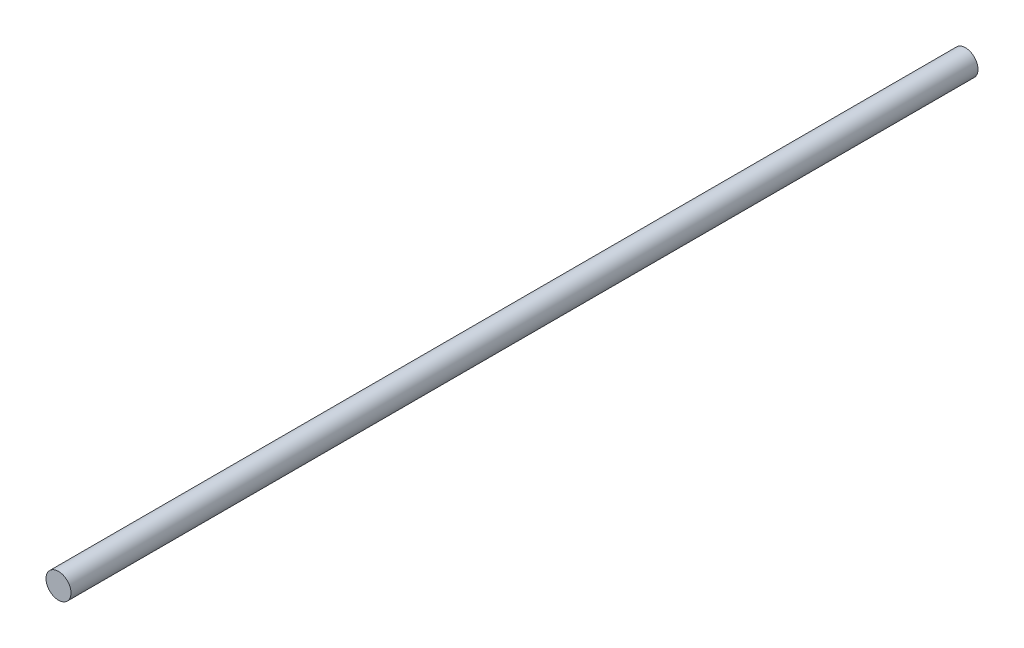
from build123d import *

# Parameters (mm, degrees)
ESQUISSE1_R        = 4
BOSS_EXTRU_1_DEPTH = 290


with BuildPart() as part:
    # Esquisse1 → Boss.-Extru.1 (new body)
    with BuildSketch(Plane.XY):
        Circle(ESQUISSE1_R)
    extrude(amount=BOSS_EXTRU_1_DEPTH)


solid = part.part
